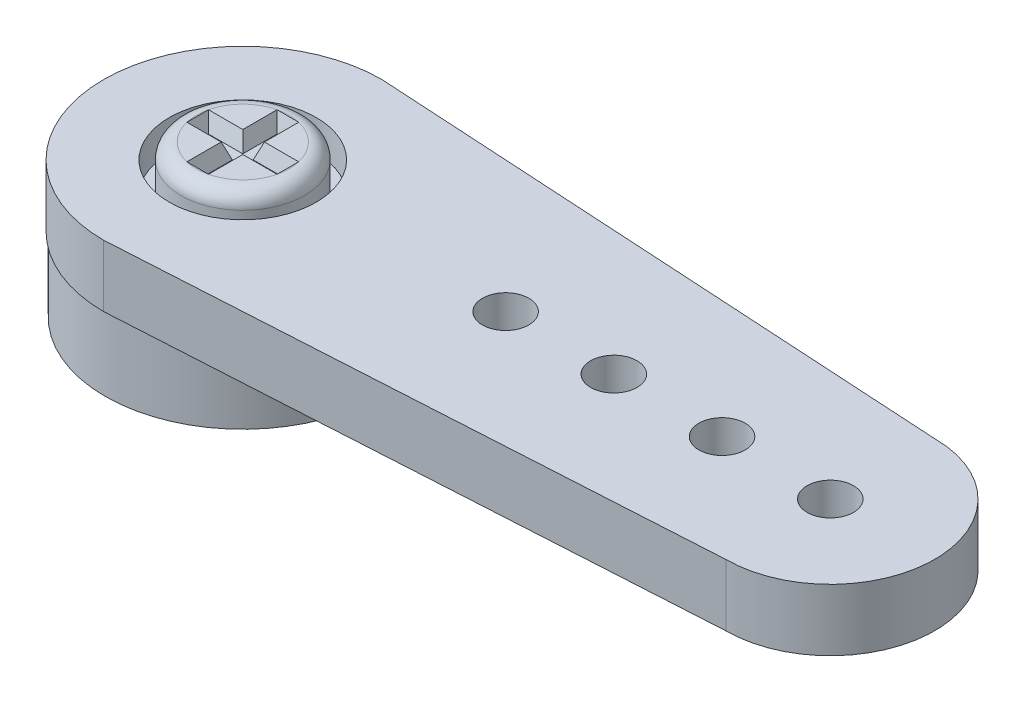
from build123d import *

# Parameters (mm, degrees)
SKETCH1_R           = 4.45
SKETCH1_R_2         = 1
BOSS_EXTRUDE1_DEPTH = 4.4
BOSS_EXTRUDE2_START = 2.4
SKETCH1_3_R         = 2.375
SKETCH1_3_R_2       = 1
SKETCH1_3_R_3       = 0.75
SKETCH1_3_R_4       = 4.45
BOSS_EXTRUDE2_DEPTH = 2
CUT_EXTRUDE1_START  = 4.4
SKETCH1_4_R         = 2.375
CUT_EXTRUDE1_DEPTH  = 1
SKETCH2_R           = 2
BOSS_EXTRUDE3_DEPTH = 1.5
FILLET1_R           = 0.5
SKETCH3_W           = 0.7
SKETCH3_H           = 2.91719043
SKETCH3_W_2         = 2.91719043
SKETCH3_H_2         = 0.7
CUT_EXTRUDE2_DEPTH  = 0.5
CUT_EXTRUDE2_TAPER  = 20
SKETCH4_R           = 2.905
CUT_EXTRUDE3_DEPTH  = 3


with BuildPart() as part:
    # Sketch1 → Boss-Extrude1 (new body)
    with BuildSketch(Plane(origin=(0, 0, 0), x_dir=(1, 0, 0), z_dir=(0, 1, 0))):
        Circle(SKETCH1_R)
        Circle(SKETCH1_R_2, mode=Mode.SUBTRACT)
    extrude(amount=BOSS_EXTRUDE1_DEPTH)

    # Sketch1_3 → Boss-Extrude2 (add)
    with BuildSketch(Plane(origin=(0, 0, 0), x_dir=(1, 0, 0), z_dir=(0, 1, 0)).offset(BOSS_EXTRUDE2_START)):
        Circle(SKETCH1_3_R)
        Circle(SKETCH1_3_R_2, mode=Mode.SUBTRACT)
        with BuildLine():
            Line((0, -4.5), (19, -3.379345653))
            ThreePointArc((19, -3.379345653), (22.379345653, 0), (19, 3.379345653))
            Line((19, 3.379345653), (0, 4.5))
            ThreePointArc((0, 4.5), (-4.5, 0), (0, -4.5))
        make_face()
        with Locations((19, 0)):
            Circle(SKETCH1_3_R_3, mode=Mode.SUBTRACT)
        with Locations((15.5, 0)):
            Circle(SKETCH1_3_R_3, mode=Mode.SUBTRACT)
        with Locations((12, 0)):
            Circle(SKETCH1_3_R_3, mode=Mode.SUBTRACT)
        with Locations((8.5, 0)):
            Circle(SKETCH1_3_R_3, mode=Mode.SUBTRACT)
        Circle(SKETCH1_3_R_4, mode=Mode.SUBTRACT)
    extrude(amount=BOSS_EXTRUDE2_DEPTH)

    # Sketch1_4 → Cut-Extrude1 (cut)
    with BuildSketch(Plane(origin=(0, 0, 0), x_dir=(1, 0, 0), z_dir=(0, 1, 0)).offset(CUT_EXTRUDE1_START)):
        Circle(SKETCH1_4_R)
    extrude(amount=-CUT_EXTRUDE1_DEPTH, mode=Mode.SUBTRACT)

    # Sketch4 → Cut-Extrude3 (cut)
    with BuildSketch(Plane.XZ):
        Circle(SKETCH4_R)
    extrude(amount=-CUT_EXTRUDE3_DEPTH, mode=Mode.SUBTRACT)


with BuildPart() as body_2:
    # Sketch2 → Boss-Extrude3 (new body)
    with BuildSketch(Plane(origin=(0, 3.4, 0), x_dir=(1, 0, 0), z_dir=(0, 1, 0))):
        Circle(SKETCH2_R)
    extrude(amount=BOSS_EXTRUDE3_DEPTH)

    # Fillet1
    fillet1_edges = [body_2.edges().sort_by_distance(p)[0] for p in [
        (-2, 4.9, 0),
    ]]
    fillet(fillet1_edges, radius=FILLET1_R)

    # Sketch3 → Cut-Extrude2 (cut)
    with BuildSketch(Plane(origin=(0, 4.9, 0), x_dir=(1, 0, 0), z_dir=(0, 1, 0))):
        Rectangle(SKETCH3_W, SKETCH3_H)
        Rectangle(SKETCH3_W_2, SKETCH3_H_2)
    extrude(amount=-CUT_EXTRUDE2_DEPTH, taper=CUT_EXTRUDE2_TAPER, mode=Mode.SUBTRACT)


solid = Compound([part.part, body_2.part])
